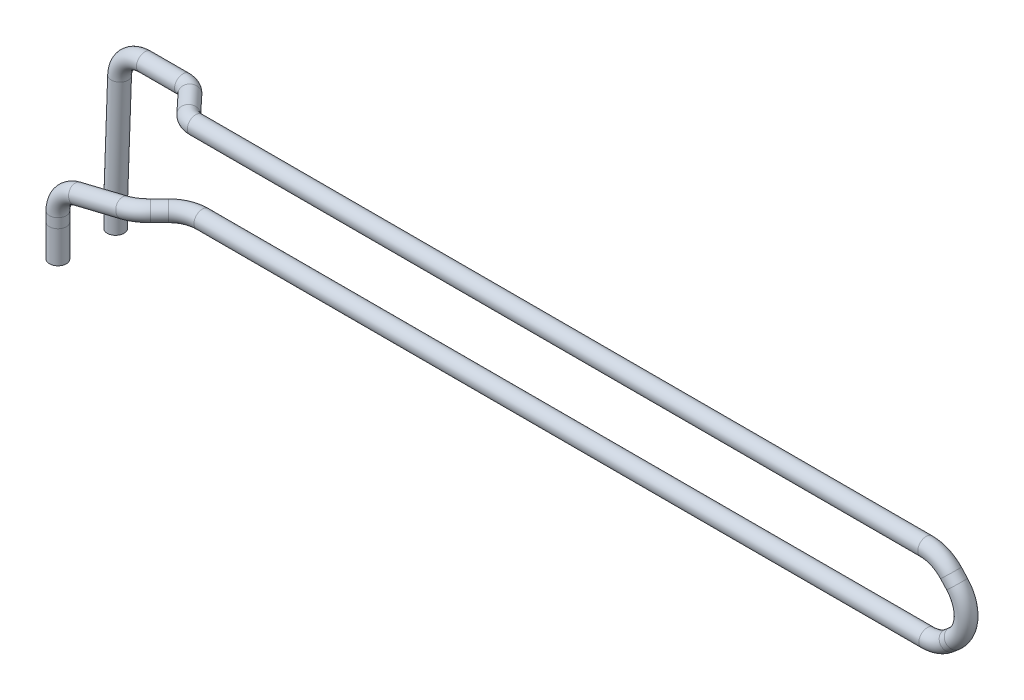
from build123d import *

# Parameters (mm, degrees)
SWEEP1_PROFILE_R = 1


with BuildPart() as part:
    # Sweep1: sweep along a curve in space
    with BuildLine() as sweep1_path:
        Line((-58.090612369, -10.590919014, 3.446712504), (-58.090612369, -14.401731911, 3.446712504))
        Line((-58.090612369, -9.4553548, 3.446712504), (-58.090612369, -10.590919014, 3.446712504))
        ThreePointArc((-58.090612369, -9.4553548, 3.446712504), (-57.449636999, -7.601978747, 3.446712504), (-55.800610506, -6.540581628, 3.446712504))
        Line((-50.195074801, -5.175151224, 3.446712504), (-55.800610506, -6.540581628, 3.446712504))
        ThreePointArc((-48.025907275, -4.86933782, 2.533008422), (-49.028684136, -4.949042, 3.208573711), (-50.195074801, -5.175151224, 3.446712504))
        Line((-48.025907275, -4.86933782, 2.533008422), (-46.944041505, -4.86933782, 1.451142652))
        ThreePointArc((-46.944041505, -4.86933782, 1.451142652), (-45.646348109, -4.86933782, 0.584051647), (-44.11561438, -4.86933782, 0.279569777))
        Line((-44.11561438, -4.86933782, 0.279569777), (41.891910563, -4.86933782, 0.279569777))
        ThreePointArc((41.891910563, -4.86933782, 0.279569777), (43.279021203, -4.621127269, 0.279569777), (44.493984095, -3.907299856, 0.279569777))
        Line((44.493984095, -3.907299856, 0.279569777), (45.097196657, -3.390636572, 0.279569777))
        ThreePointArc((45.097196657, -3.390636572, 0.279569777), (46.488619757, -0.580675967, 0.279569777), (45.42605494, 2.369390618, 0.279569777))
        Line((45.42605494, 2.369390618, 0.279569777), (44.692451893, 3.159283727, 0.279569777))
        ThreePointArc((41.761520079, 4.437218573, 0.279569777), (43.360228837, 4.103842403, 0.279569777), (44.692451893, 3.159283727, 0.279569777))
        Line((41.761520079, 4.437218573, 0.279569777), (-44.906338407, 4.437218573, 0.279569777))
        ThreePointArc((-44.906338407, 4.437218573, 0.279569777), (-45.702437865, 4.437218573, 0.114297455), (-46.366964117, 4.437218573, -0.35420457))
        Line((-46.366964117, 4.437218573, -0.35420457), (-48.399983368, 4.437218573, -2.527696321))
        ThreePointArc((-49.860609078, 4.437218573, -3.161470668), (-49.06450962, 4.437218573, -2.996198346), (-48.399983368, 4.437218573, -2.527696321))
        Line((-49.860609078, 4.437218573, -3.161470668), (-54.382636754, 4.437218573, -3.161470668))
        ThreePointArc((-57.380734796, 1.544027447, -3.161470668), (-56.465852223, 3.595971294, -3.161470668), (-54.382636754, 4.437218573, -3.161470668))
        Line((-57.380734796, 1.544027447, -3.161470668), (-57.847768858, -11.56550035, -3.161470668))
        Line((-57.847768858, -11.56550035, -3.161470668), (-57.847768858, -14.450426845, -3.161470668))
    # Sweep1 profile (on start of the path) → Sweep1 (sweep)
    with BuildSketch(Plane(origin=(-57.847768858, -14.450426845, -3.161470668), x_dir=(0, 0, 1), z_dir=(0, 1, 0))):
        Circle(SWEEP1_PROFILE_R)
    sweep(path=sweep1_path.line, transition=Transition.RIGHT)


solid = part.part
